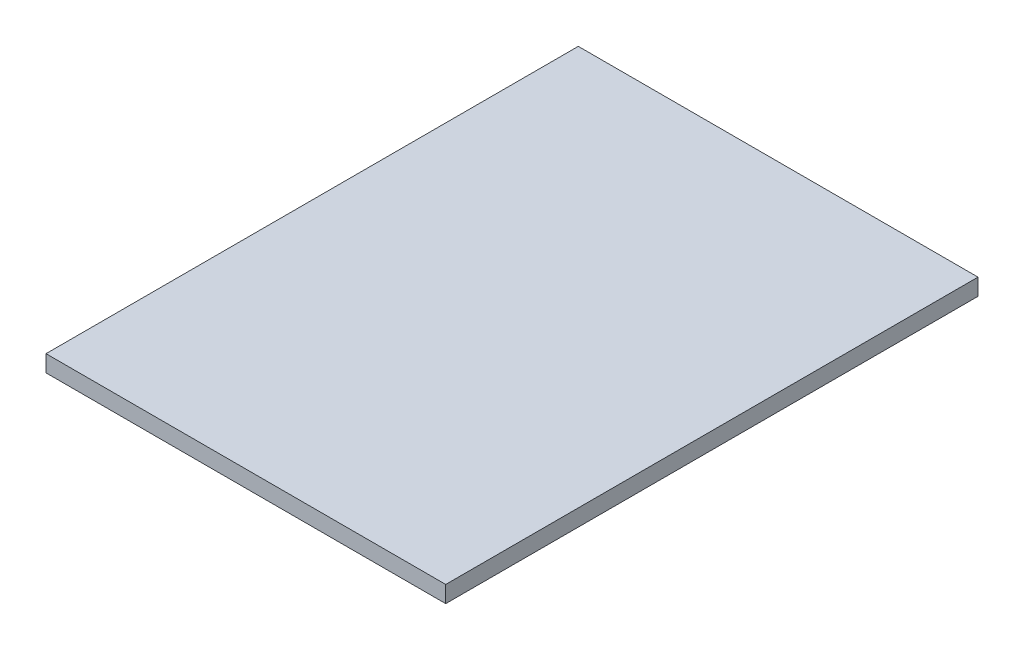
from build123d import *

# Parameters (mm, degrees)
SKETCH3_W           = 152.4
SKETCH3_H           = 202.946
BOSS_EXTRUDE1_DEPTH = 6.35


with BuildPart() as part:
    # Sketch3 → Boss-Extrude1 (new body)
    with BuildSketch(Plane(origin=(0, 0, 0), x_dir=(1, 0, 0), z_dir=(0, 1, 0))):
        with Locations((76.2, 101.473)):
            Rectangle(SKETCH3_W, SKETCH3_H)
    extrude(amount=BOSS_EXTRUDE1_DEPTH)


solid = part.part
